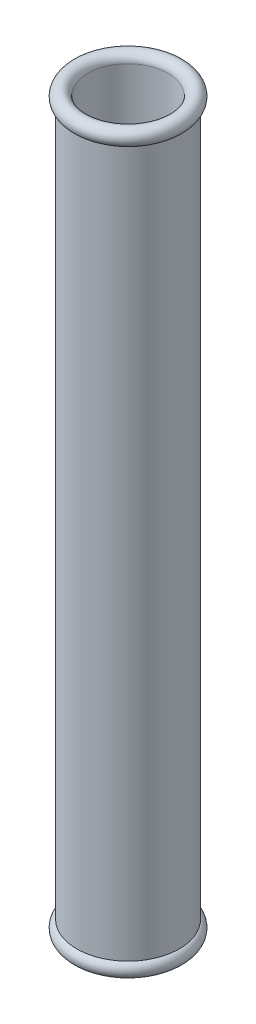
from build123d import *


with BuildPart() as part:
    # Sketch1 → Revolve2 (revolve)
    with BuildSketch(Plane.XY):
        with BuildLine():
            ThreePointArc((2.25, 0.316227766), (1.912917131, 0.295803989), (1.75, 0))
            Line((1.75, 0), (2.25, 0))
            Line((2.25, 0), (2.25, 0.316227766))
        make_face()
        with BuildLine():
            Line((2.25, 0), (1.75, 0))
            ThreePointArc((1.75, 0), (2.1, -0.35), (2.45, 0))
            ThreePointArc((2.45, 0), (2.395803989, 0.187082869), (2.25, 0.316227766))
            Line((2.25, 0.316227766), (2.25, 0))
        make_face()
        with BuildLine():
            Line((1.75, 31.6), (1.75, 0))
            ThreePointArc((1.75, 0), (1.912917131, 0.295803989), (2.25, 0.316227766))
            Line((2.25, 0.316227766), (2.25, 31.283772234))
            ThreePointArc((2.25, 31.283772234), (1.912917131, 31.304196011), (1.75, 31.6))
        make_face()
        with BuildLine():
            ThreePointArc((2.45, 31.6), (2.1, 31.95), (1.75, 31.6))
            Line((1.75, 31.6), (2.25, 31.6))
            Line((2.25, 31.6), (2.25, 31.283772234))
            ThreePointArc((2.25, 31.283772234), (2.395803989, 31.412917131), (2.45, 31.6))
        make_face()
        with BuildLine():
            Line((2.25, 31.6), (1.75, 31.6))
            ThreePointArc((1.75, 31.6), (1.912917131, 31.304196011), (2.25, 31.283772234))
            Line((2.25, 31.283772234), (2.25, 31.6))
        make_face()
    revolve(axis=Axis((0, 0, 0), (0, 1, 0)))


solid = part.part
